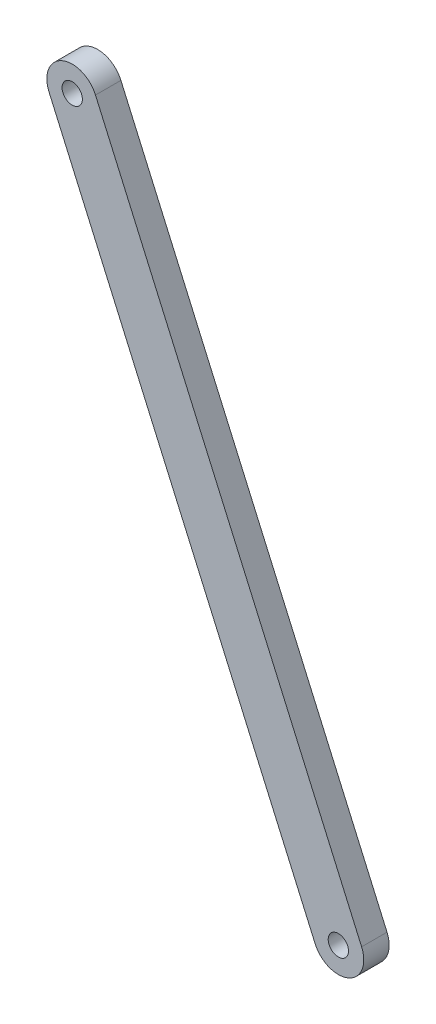
from build123d import *

# Parameters (mm, degrees)
BOSS_EXTRUDE1_START = -5
SKETCH1_R           = 2
BOSS_EXTRUDE1_DEPTH = 5


with BuildPart() as part:
    # Sketch1 → Boss-Extrude1 (new body)
    with BuildSketch(Plane.XY.offset(BOSS_EXTRUDE1_START)):
        with BuildLine():
            Line((-74.811187919, 158.283111414), (-22.442309188, 39.297815934))
            ThreePointArc((-22.442309188, 39.297815934), (-25.004479063, 32.707270772), (-31.595024225, 35.269440647))
            Line((-31.595024225, 35.269440647), (-83.963902956, 154.254736127))
            ThreePointArc((-83.963902956, 154.254736127), (-81.401733081, 160.845281289), (-74.811187919, 158.283111414))
        make_face()
        with Locations((-79.387545438, 156.26892377)):
            Circle(SKETCH1_R, mode=Mode.SUBTRACT)
        with Locations((-27.018666706, 37.283628291)):
            Circle(SKETCH1_R, mode=Mode.SUBTRACT)
    extrude(amount=-BOSS_EXTRUDE1_DEPTH)


solid = part.part
